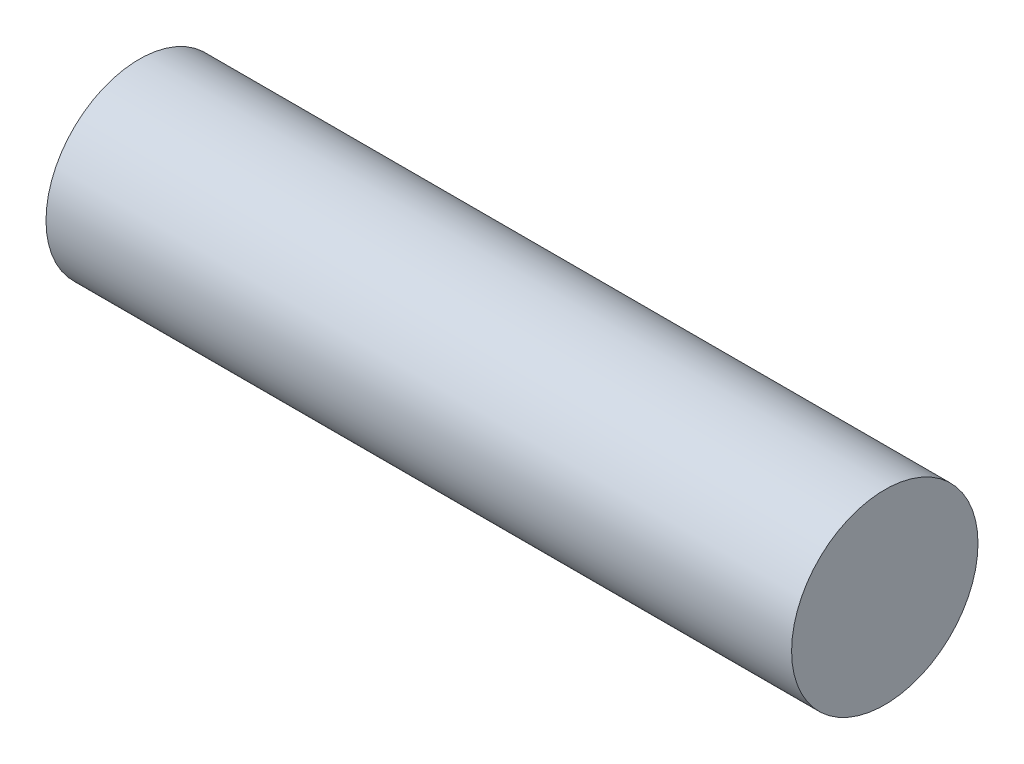
from build123d import *

# Parameters (mm, degrees)
SKETCH1_R           = 5
BOSS_EXTRUDE1_DEPTH = 40


with BuildPart() as part:
    # Sketch1 → Boss-Extrude1 (new body)
    with BuildSketch(Plane(origin=(0, 0, 0), x_dir=(0, 0, -1), z_dir=(1, 0, 0))):
        Circle(SKETCH1_R)
    extrude(amount=BOSS_EXTRUDE1_DEPTH)


solid = part.part
